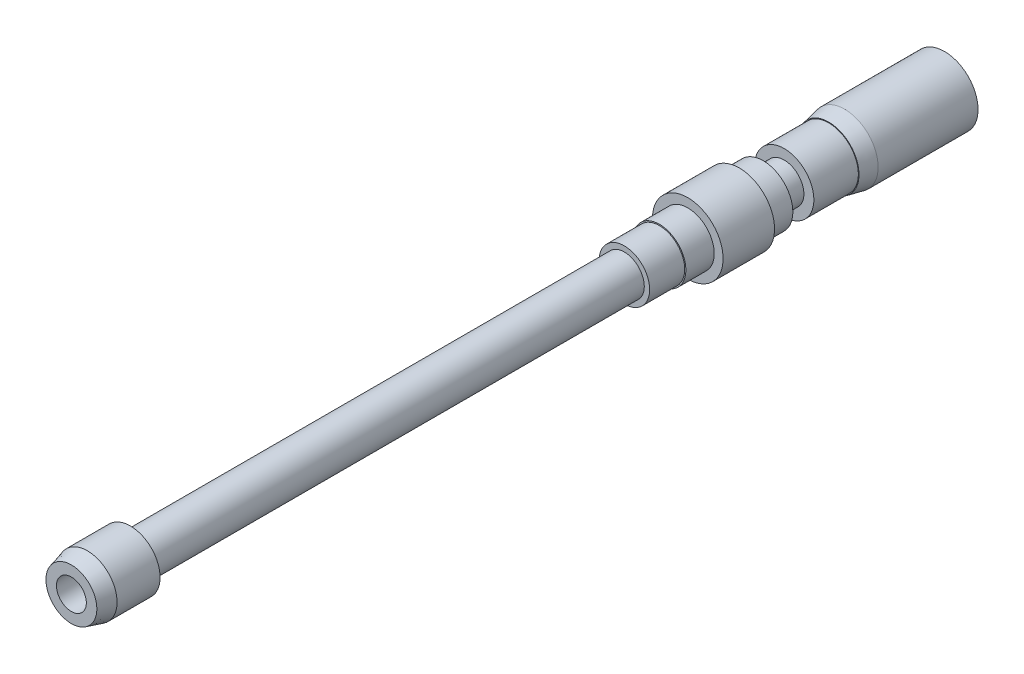
from build123d import *

# Parameters (mm, degrees)
SKETCH1_R           = 4.7371
BOSS_EXTRUDE1_DEPTH = 9.398
SKETCH2_R           = 3.175
BOSS_EXTRUDE2_DEPTH = 78.74
SKETCH3_R           = 4.0259
BOSS_EXTRUDE3_DEPTH = 5.588
SKETCH4_R           = 4.2164
BOSS_EXTRUDE4_DEPTH = 4.5212
SKETCH5_R           = 5.6261
BOSS_EXTRUDE5_DEPTH = 8.2042
SKETCH6_R           = 4.7244
BOSS_EXTRUDE6_DEPTH = 3.81
SKETCH7_R           = 3.1369
BOSS_EXTRUDE7_DEPTH = 3.3528
SKETCH8_R           = 4.7244
BOSS_EXTRUDE8_DEPTH = 7.0866
SKETCH9_R           = 5.3467
BOSS_EXTRUDE9_DEPTH = 18.4658
CHAMFER3_SIZE       = 0.508
CHAMFER3_SIZE2      = 2.54
CHAMFER4_SIZE       = 2.54
CHAMFER4_SIZE2      = 0.680590949
SKETCH10_R          = 2.38125
CUT_EXTRUDE1_DEPTH  = 139.1666


with BuildPart() as part:
    # Sketch1 → Boss-Extrude1 (new body)
    with BuildSketch(Plane.XY):
        Circle(SKETCH1_R)
    extrude(amount=-BOSS_EXTRUDE1_DEPTH)

    # Sketch2 → Boss-Extrude2 (add)
    with BuildSketch(Plane(origin=(0, 0, -9.398), x_dir=(-1, 0, 0), z_dir=(0, 0, -1))):
        Circle(SKETCH2_R)
    extrude(amount=BOSS_EXTRUDE2_DEPTH)

    # Sketch3 → Boss-Extrude3 (add)
    with BuildSketch(Plane(origin=(0, 0, -88.138), x_dir=(-1, 0, 0), z_dir=(0, 0, -1))):
        Circle(SKETCH3_R)
    extrude(amount=BOSS_EXTRUDE3_DEPTH)

    # Sketch4 → Boss-Extrude4 (add)
    with BuildSketch(Plane(origin=(0, 0, -93.726), x_dir=(-1, 0, 0), z_dir=(0, 0, -1))):
        Circle(SKETCH4_R)
    extrude(amount=BOSS_EXTRUDE4_DEPTH)

    # Sketch5 → Boss-Extrude5 (add)
    with BuildSketch(Plane(origin=(0, 0, -98.2472), x_dir=(-1, 0, 0), z_dir=(0, 0, -1))):
        Circle(SKETCH5_R)
    extrude(amount=BOSS_EXTRUDE5_DEPTH)

    # Sketch6 → Boss-Extrude6 (add)
    with BuildSketch(Plane(origin=(0, 0, -106.4514), x_dir=(-1, 0, 0), z_dir=(0, 0, -1))):
        Circle(SKETCH6_R)
    extrude(amount=BOSS_EXTRUDE6_DEPTH)

    # Sketch7 → Boss-Extrude7 (add)
    with BuildSketch(Plane(origin=(0, 0, -110.2614), x_dir=(-1, 0, 0), z_dir=(0, 0, -1))):
        Circle(SKETCH7_R)
    extrude(amount=BOSS_EXTRUDE7_DEPTH)

    # Sketch8 → Boss-Extrude8 (add)
    with BuildSketch(Plane(origin=(0, 0, -113.6142), x_dir=(-1, 0, 0), z_dir=(0, 0, -1))):
        Circle(SKETCH8_R)
    extrude(amount=BOSS_EXTRUDE8_DEPTH)

    # Sketch9 → Boss-Extrude9 (add)
    with BuildSketch(Plane(origin=(0, 0, -120.7008), x_dir=(-1, 0, 0), z_dir=(0, 0, -1))):
        Circle(SKETCH9_R)
    extrude(amount=BOSS_EXTRUDE9_DEPTH)

    # Chamfer3
    chamfer3_edges = [part.edges().sort_by_distance(p)[0] for p in [
        (5.3467, 0, -120.7008),
    ]]
    chamfer3_side = [part.faces().sort_by_distance(p)[0] for p in [
        (5.195472487, 0, -120.7008),
    ]]
    chamfer(chamfer3_edges, length=CHAMFER3_SIZE, length2=CHAMFER3_SIZE2, reference=chamfer3_side[0])

    # Chamfer4
    chamfer4_edges = [part.edges().sort_by_distance(p)[0] for p in [
        (-4.7371, 0, 0),
    ]]
    chamfer4_side = [part.faces().sort_by_distance(p)[0] for p in [
        (-4.7371, 0, -4.699),
    ]]
    chamfer(chamfer4_edges, length=CHAMFER4_SIZE, length2=CHAMFER4_SIZE2, reference=chamfer4_side[0])

    # Sketch10 → Cut-Extrude1 (cut)
    with BuildSketch(Plane.XY):
        Circle(SKETCH10_R)
    extrude(amount=-CUT_EXTRUDE1_DEPTH, mode=Mode.SUBTRACT)


solid = part.part
